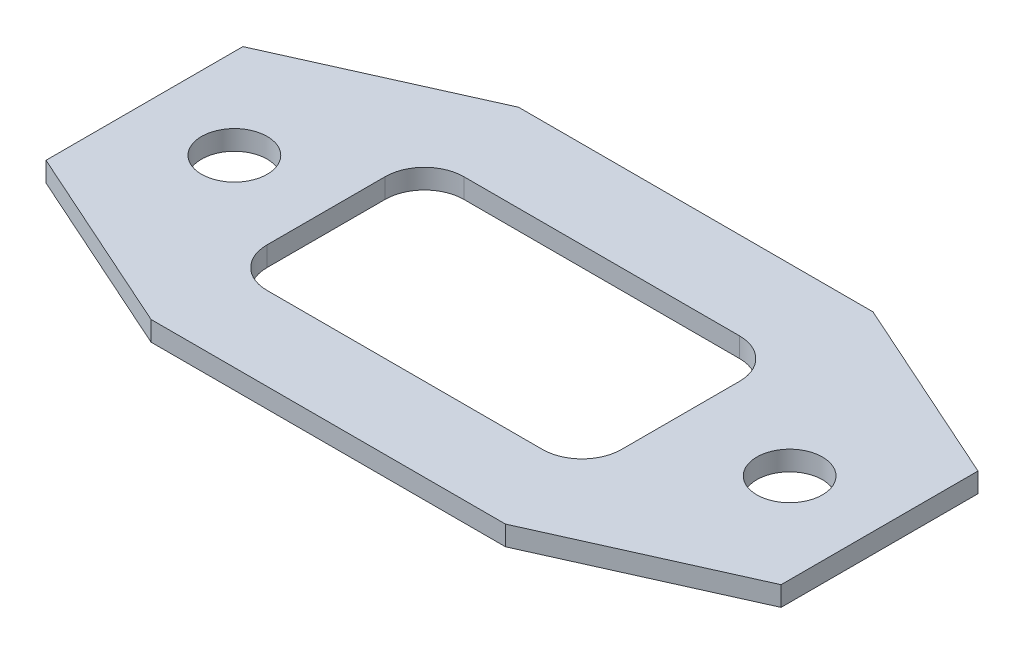
from build123d import *

# Parameters (mm, degrees)
SKETCH1_R           = 2.5
BOSS_EXTRUDE1_DEPTH = 1.5


with BuildPart() as part:
    # Sketch1 → Boss-Extrude1 (new body)
    with BuildSketch(Plane(origin=(0, 0, 0), x_dir=(1, 0, 0), z_dir=(0, 1, 0))):
        Polygon((-13.5, 14), (13.5, 14), (28, 7.5), (28, -7.5), (13.5, -14), (-13.5, -14), (-28, -7.5), (-28, 7.5), align=None)
        with Locations((21.15, 0)):
            Circle(SKETCH1_R, mode=Mode.SUBTRACT)
        with Locations((-21.15, 0)):
            Circle(SKETCH1_R, mode=Mode.SUBTRACT)
        with BuildLine():
            Line((13, 4.333683406), (13, -4.666316594))
            ThreePointArc((13, -4.666316594), (12.121320344, -6.787636938), (10, -7.666316594))
            Line((10, -7.666316594), (-11, -7.666316594))
            ThreePointArc((-11, -7.666316594), (-13.121320344, -6.787636938), (-14, -4.666316594))
            Line((-14, -4.666316594), (-14, 4.333683406))
            ThreePointArc((-14, 4.333683406), (-13.121320344, 6.455003749), (-11, 7.333683406))
            Line((-11, 7.333683406), (10, 7.333683406))
            ThreePointArc((10, 7.333683406), (12.121320344, 6.455003749), (13, 4.333683406))
        make_face(mode=Mode.SUBTRACT)
    extrude(amount=BOSS_EXTRUDE1_DEPTH)


solid = part.part
